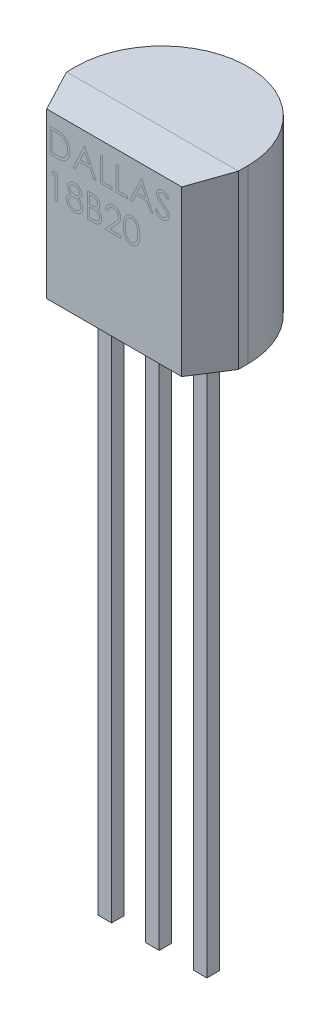
from build123d import *

# Parameters (mm, degrees)
BOSS_EXTRUDE1_DEPTH = 4.58
SKETCH2_W           = 4.58
SKETCH2_H           = 4.58
SKETCH3_W           = 3.6
SKETCH3_H           = 4.38
SKETCH4_W           = 0.36
SKETCH4_H           = 0.33
BOSS_EXTRUDE2_DEPTH = 14.47
SKETCH7_R           = 0.763333333
CUT_EXTRUDE1_DEPTH  = 0.25


with BuildPart() as part:
    # Sketch1 → Boss-Extrude1 (new body)
    with BuildSketch(Plane(origin=(0, 0, 0), x_dir=(1, 0, 0), z_dir=(0, 1, 0))):
        with BuildLine():
            Line((-2.29, 0), (-2.29, -0.25))
            Line((-2.29, -0.25), (2.29, -0.25))
            Line((2.29, -0.25), (2.29, 0))
            ThreePointArc((2.29, 0), (0, 2.29), (-2.29, 0))
        make_face()
    extrude(amount=BOSS_EXTRUDE1_DEPTH)

    # Sketch2 → Loft1 section 0
    with BuildSketch(Plane.XY.offset(0.25)):
        with Locations((0, 2.29)):
            Rectangle(SKETCH2_W, SKETCH2_H)
    # Sketch3 → Loft1 section 1
    with BuildSketch(Plane.XY.offset(1.27)):
        with Locations((0, 2.29)):
            Rectangle(SKETCH3_W, SKETCH3_H)
    loft()

    # Sketch4 → Boss-Extrude2 (add)
    with BuildSketch(Plane.XZ):
        with Locations((0, 0.085)):
            Rectangle(SKETCH4_W, SKETCH4_H)
        with Locations((-1.27, 0.085)):
            Rectangle(SKETCH4_W, SKETCH4_H)
        with Locations((1.27, 0.085)):
            Rectangle(SKETCH4_W, SKETCH4_H)
    extrude(amount=BOSS_EXTRUDE2_DEPTH)

    # Sketch7 → Cut-Extrude1 (cut)
    with BuildSketch(Plane.XY.offset(-2.29)):
        with Locations((0, 2.29)):
            Circle(SKETCH7_R)
    extrude(amount=CUT_EXTRUDE1_DEPTH, mode=Mode.SUBTRACT)


solid = part.part
